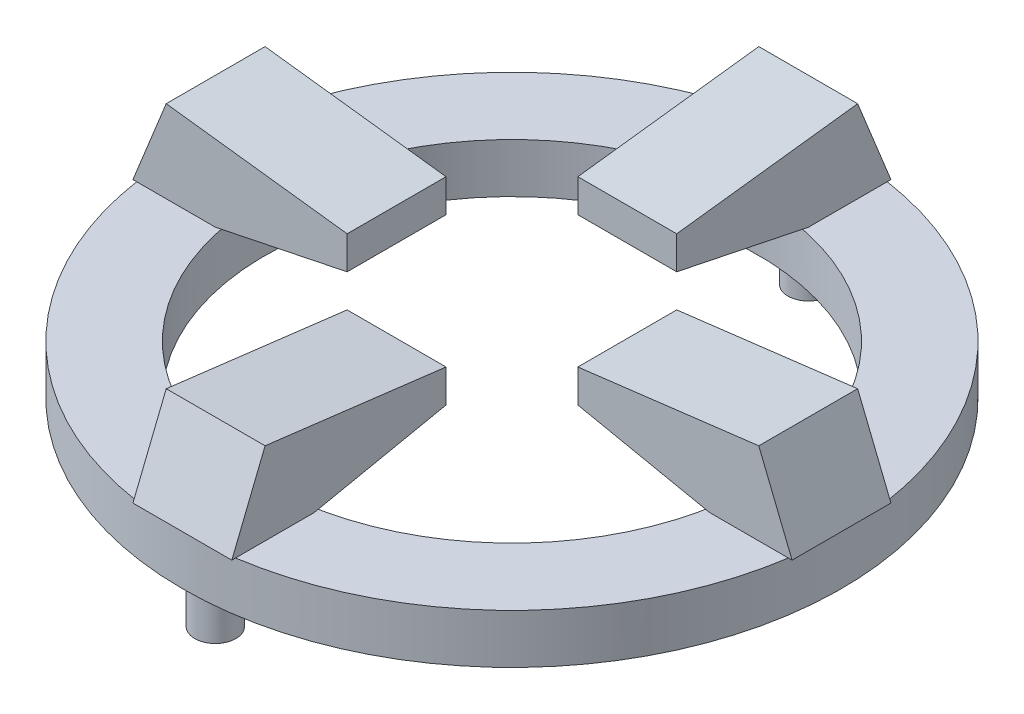
from build123d import *

# Parameters (mm, degrees)
SKETCH1_R                = 20
SKETCH1_R_2              = 15
BOSS_EXTRUDE1_DEPTH      = 3
BOSS_EXTRUDE2_DEPTH      = 3
BOSS_EXTRUDE2_DEPTH_BACK = 3
BOSS_EXTRUDE3_DEPTH      = 3
BOSS_EXTRUDE3_DEPTH_BACK = 3
SKETCH4_R                = 1.25
BOSS_EXTRUDE4_DEPTH      = 3


with BuildPart() as part:
    # Sketch1 → Boss-Extrude1 (new body)
    with BuildSketch(Plane(origin=(0, 0, 0), x_dir=(1, 0, 0), z_dir=(0, 1, 0))):
        Circle(SKETCH1_R)
        Circle(SKETCH1_R_2, mode=Mode.SUBTRACT)
    extrude(amount=BOSS_EXTRUDE1_DEPTH)

    # Sketch2 → Boss-Extrude2 (add, two sides: drawn at the far end of the back side and taken through both)
    with BuildSketch(Plane(origin=(0, 0, 0), x_dir=(0, 0, -1), z_dir=(1, 0, 0)).offset(-BOSS_EXTRUDE2_DEPTH_BACK)):
        Polygon((20, 3), (17.979868871, 8), (7, 6.651841622), (7, 4.651841622), (15, 3), align=None)
        Polygon((-7, 4.651841622), (-15, 3), (-20, 3), (-17.979868871, 8), (-7, 6.651841622), align=None)
    extrude(amount=BOSS_EXTRUDE2_DEPTH + BOSS_EXTRUDE2_DEPTH_BACK)

    # Sketch3 → Boss-Extrude3 (add, two sides: drawn at the far end of the back side and taken through both)
    with BuildSketch(Plane.XY.offset(-BOSS_EXTRUDE3_DEPTH_BACK)):
        Polygon((20, 3), (17.979868871, 8), (7, 6.651841622), (7, 4.651841622), (15, 3), align=None)
        Polygon((-7, 4.651841622), (-15, 3), (-20, 3), (-17.979868871, 8), (-7, 6.651841622), align=None)
    extrude(amount=BOSS_EXTRUDE3_DEPTH + BOSS_EXTRUDE3_DEPTH_BACK)

    # Sketch4 → Boss-Extrude4 (add)
    with BuildSketch(Plane.XZ):
        with Locations((0, 18)):
            Circle(SKETCH4_R)
        with Locations((0, -18)):
            Circle(SKETCH4_R)
    extrude(amount=BOSS_EXTRUDE4_DEPTH)


solid = part.part
